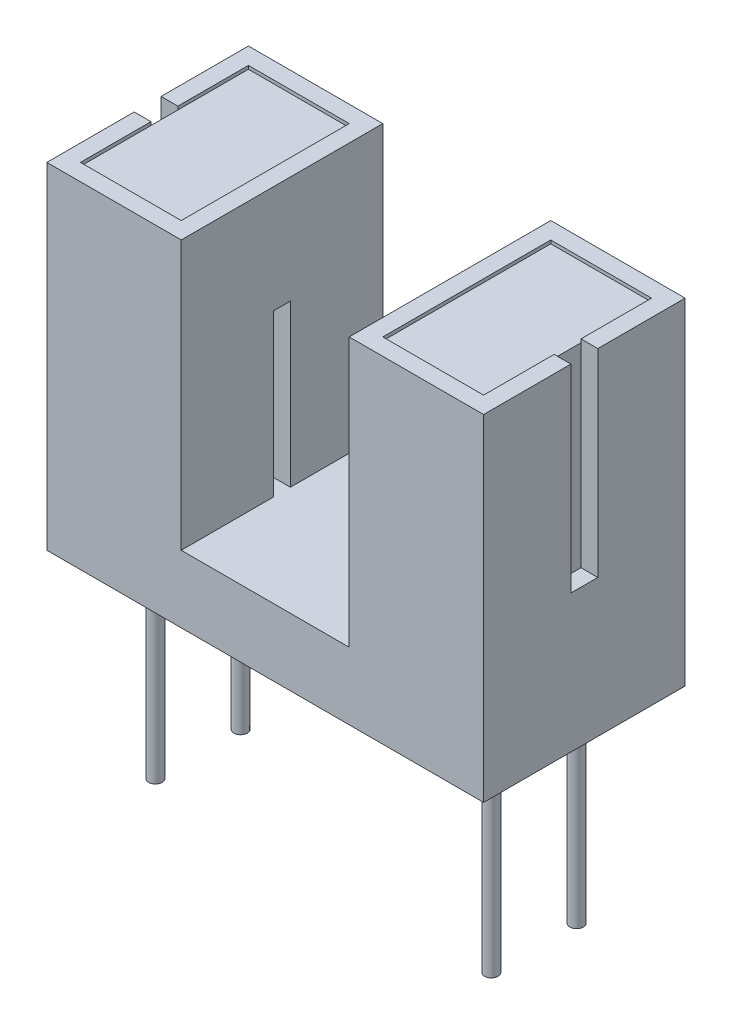
from build123d import *

# Parameters (mm, degrees)
ESBO_O2_W                = 13
ESBO_O2_H                = 6
RESSALTO_EXTRUS_O1_DEPTH = 10
ESBO_O3_W                = 5
ESBO_O3_H                = 6
CORTE_EXTRUS_O1_DEPTH    = 8
ESBO_O4_W                = 3
ESBO_O4_H                = 5
CORTE_EXTRUS_O2_DEPTH    = 0.1
ESBO_O5_W                = 1
ESBO_O5_H                = 0.8
CORTE_EXTRUS_O3_DEPTH    = 5.9
ESBO_O6_W                = 1
ESBO_O6_H                = 0.5
CORTE_EXTRUS_O4_DEPTH    = 4.8
ESBO_O7_R                = 0.2
RESSALTO_EXTRUS_O2_DEPTH = 6


with BuildPart() as part:
    # Esboço2 → Ressalto-extrusão1 (new body)
    with BuildSketch(Plane(origin=(0, 0, 0), x_dir=(1, 0, 0), z_dir=(0, 1, 0))):
        Rectangle(ESBO_O2_W, ESBO_O2_H)
    extrude(amount=RESSALTO_EXTRUS_O1_DEPTH)

    # Esboço3 → Corte-extrusão1 (cut)
    with BuildSketch(Plane(origin=(0, 10, 0), x_dir=(1, 0, 0), z_dir=(0, 1, 0))):
        Rectangle(ESBO_O3_W, ESBO_O3_H)
    extrude(amount=-CORTE_EXTRUS_O1_DEPTH, mode=Mode.SUBTRACT)

    # Esboço4 → Corte-extrusão2 (cut)
    with BuildSketch(Plane(origin=(0, 10, 0), x_dir=(1, 0, 0), z_dir=(0, 1, 0))):
        with Locations((-4.5, 0)):
            Rectangle(ESBO_O4_W, ESBO_O4_H)
    corte_extrus_o2 = extrude(amount=-CORTE_EXTRUS_O2_DEPTH, mode=Mode.SUBTRACT)

    # Espelhar1: Corte-extrusão2 across plane
    add(corte_extrus_o2.mirror(Plane(origin=(0, 0, 0), x_dir=(0, 0, 1), z_dir=(1, 0, 0))), mode=Mode.SUBTRACT)

    # Esboço5 → Corte-extrusão3 (cut)
    with BuildSketch(Plane(origin=(0, 10, 0), x_dir=(1, 0, 0), z_dir=(0, 1, 0))):
        with Locations((-6.5, 0)):
            Rectangle(ESBO_O5_W, ESBO_O5_H)
    corte_extrus_o3 = extrude(amount=-CORTE_EXTRUS_O3_DEPTH, mode=Mode.SUBTRACT)

    # Espelhar2: Corte-extrusão3 across plane
    add(corte_extrus_o3.mirror(Plane(origin=(0, 0, 0), x_dir=(0, 0, 1), z_dir=(1, 0, 0))), mode=Mode.SUBTRACT)

    # Esboço6 → Corte-extrusão4 (cut)
    with BuildSketch(Plane(origin=(0, 6.8, 0), x_dir=(1, 0, 0), z_dir=(0, 1, 0))):
        with Locations((-2.5, 0)):
            Rectangle(ESBO_O6_W, ESBO_O6_H)
    corte_extrus_o4 = extrude(amount=-CORTE_EXTRUS_O4_DEPTH, mode=Mode.SUBTRACT)

    # Espelhar3: Corte-extrusão4 across plane
    add(corte_extrus_o4.mirror(Plane(origin=(0, 0, 0), x_dir=(0, 0, 1), z_dir=(1, 0, 0))), mode=Mode.SUBTRACT)

    # Esboço7 → Ressalto-extrusão2 (add)
    with BuildSketch(Plane.XZ):
        with Locations((-5, 1.27)):
            Circle(ESBO_O7_R)
        with Locations((5, 1.27)):
            Circle(ESBO_O7_R)
        with Locations((5, -1.27)):
            Circle(ESBO_O7_R)
        with Locations((-5, -1.27)):
            Circle(ESBO_O7_R)
    extrude(amount=RESSALTO_EXTRUS_O2_DEPTH)


solid = part.part
